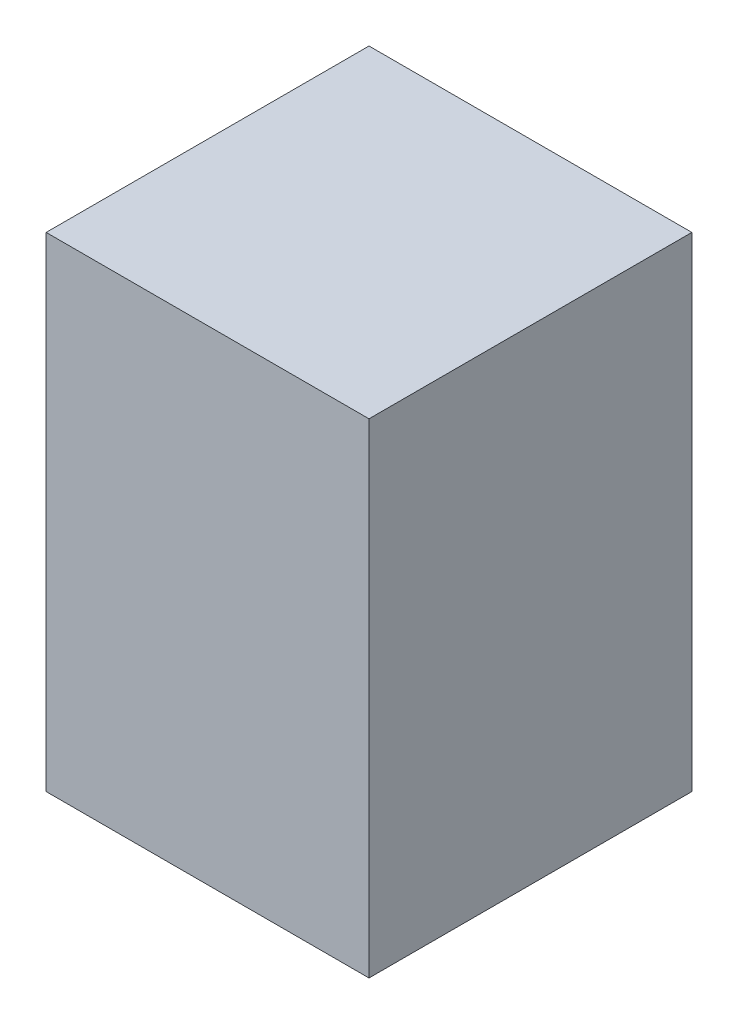
from build123d import *

# Parameters (mm, degrees)
SKETCH2_W           = 203.2
SKETCH2_H           = 203.2
BOSS_EXTRUDE1_DEPTH = 304.8


with BuildPart() as part:
    # Sketch2 → Boss-Extrude1 (new body)
    with BuildSketch(Plane(origin=(0, 0, 0), x_dir=(1, 0, 0), z_dir=(0, 1, 0))):
        with Locations((-80.962007996, -29.135294118)):
            Rectangle(SKETCH2_W, SKETCH2_H)
    extrude(amount=BOSS_EXTRUDE1_DEPTH)


solid = part.part
